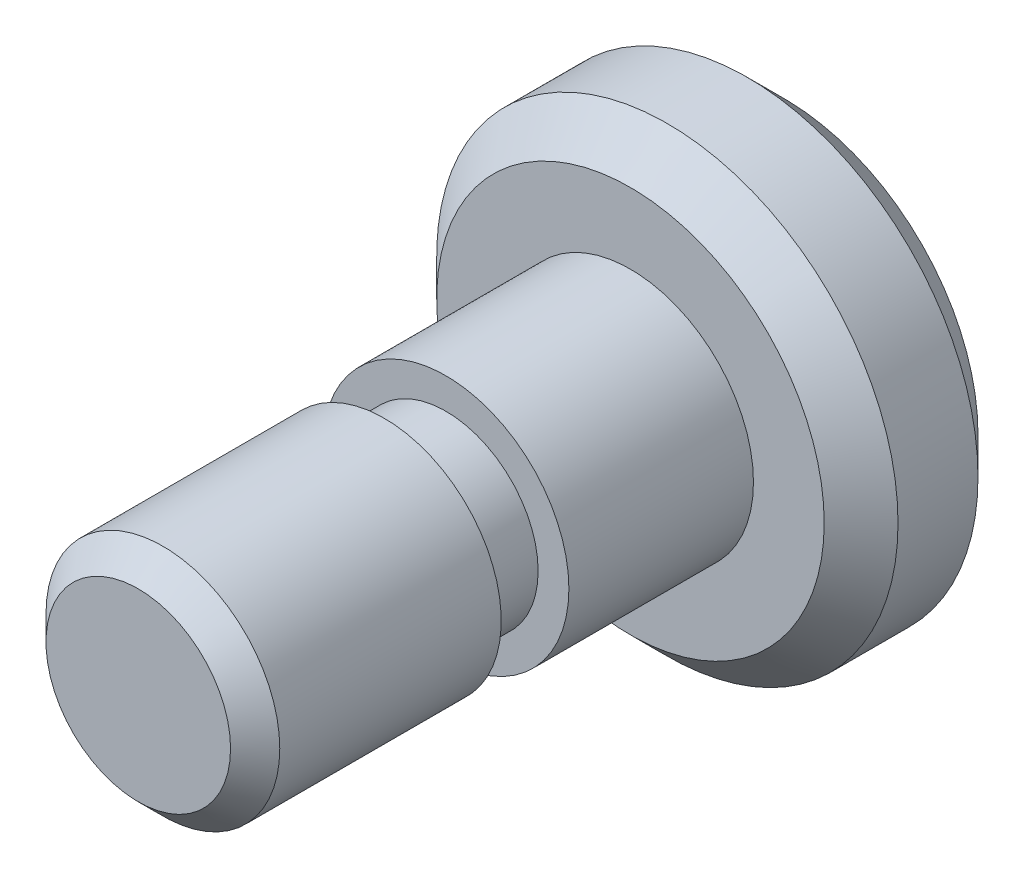
from build123d import *

# Parameters (mm, degrees)
SKETCH1_R           = 4.7625
BOSS_EXTRUDE1_DEPTH = 3.175
SKETCH2_R           = 2.54
BOSS_EXTRUDE2_DEPTH = 3.81
SKETCH3_R           = 2.413
BOSS_EXTRUDE3_DEPTH = 6.35
CHAMFER1_SIZE       = 0.508
SKETCH8_W           = 0.635
SKETCH8_H           = 1.27
CHAMFER2_SIZE       = 0.762


with BuildPart() as part:
    # Sketch1 → Boss-Extrude1 (new body)
    with BuildSketch(Plane.XY):
        Circle(SKETCH1_R)
    extrude(amount=BOSS_EXTRUDE1_DEPTH)

    # Sketch2 → Boss-Extrude2 (add)
    with BuildSketch(Plane.XY.offset(3.175)):
        Circle(SKETCH2_R)
    extrude(amount=BOSS_EXTRUDE2_DEPTH)

    # Sketch3 → Boss-Extrude3 (add)
    with BuildSketch(Plane.XY.offset(6.985)):
        Circle(SKETCH3_R)
    extrude(amount=BOSS_EXTRUDE3_DEPTH)

    # Chamfer1
    chamfer1_edges = [part.edges().sort_by_distance(p)[0] for p in [
        (-2.413, 0, 13.335),
    ]]
    chamfer(chamfer1_edges, length=CHAMFER1_SIZE)

    # Sketch8 → Cut-Revolve1 (revolve, cut)
    with BuildSketch(Plane(origin=(0, 0, 0), x_dir=(1, 0, 0), z_dir=(0, 1, 0))):
        with Locations((-2.2225, -7.62)):
            Rectangle(SKETCH8_W, SKETCH8_H)
    revolve(axis=Axis((0, 0, 23.053781971), (0, 0, -1)), mode=Mode.SUBTRACT)

    # Chamfer2
    chamfer2_edges = [part.edges().sort_by_distance(p)[0] for p in [
        (-4.7625, 0, 0),
        (-4.7625, 0, 3.175),
    ]]
    chamfer(chamfer2_edges, length=CHAMFER2_SIZE)


solid = part.part
